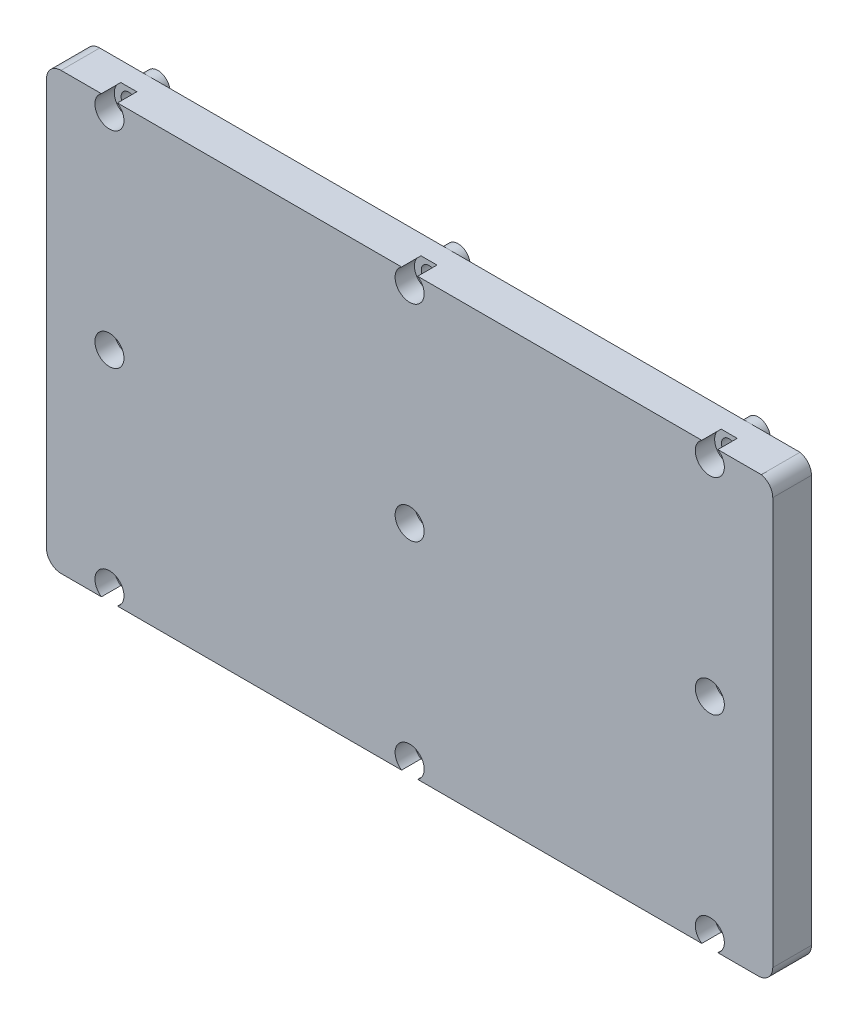
from build123d import *

# Parameters (mm, degrees)
BOSS_EXTRU_1_DEPTH           = 8
ESQUISSE14_R                 = 1.6
ENL_V_MAT_EXTRU_2_DEPTH      = 1
ENL_V_MAT_EXTRU_2_DEPTH_BACK = 9
ESQUISSE15_R                 = 3
ENL_V_MAT_EXTRU_3_DEPTH      = 4
ESQUISSE16_R                 = 2.5
BOSS_EXTRU_3_DEPTH           = 2
ESQUISSE17_R                 = 1.6
ENL_V_MAT_EXTRU_4_DEPTH      = 11


with BuildPart() as part:
    # Esquisse1 → Boss.-Extru.1 (new body)
    with BuildSketch(Plane.XY):
        with BuildLine():
            Line((2.96841177, 10.030192742), (146.96841177, 10.030192742))
            ThreePointArc((146.96841177, 10.030192742), (149.089732114, 10.908872398), (149.96841177, 13.030192742))
            Line((149.96841177, 13.030192742), (149.96841177, 97.09690847))
            ThreePointArc((149.96841177, 97.09690847), (149.301594422, 98.982712998), (147.597572626, 100.030192742))
            Line((147.597572626, 100.030192742), (2.96841177, 100.030192742))
            ThreePointArc((2.96841177, 100.030192742), (0.847091427, 99.151513085), (-0.03158823, 97.030192742))
            Line((-0.03158823, 97.030192742), (-0.03158823, 13.030192742))
            ThreePointArc((-0.03158823, 13.030192742), (0.847091427, 10.908872398), (2.96841177, 10.030192742))
        make_face()
    extrude(amount=BOSS_EXTRU_1_DEPTH)

    # Esquisse14 → Enlèv. mat.-Extru.2 (cut, two sides)
    with BuildSketch(Plane.XY.offset(8)) as enl_v_mat_extru_2_sk:
        with Locations((12.96841177, 97.530192742)):
            Circle(ESQUISSE14_R)
        with Locations((74.96841177, 97.530192742)):
            Circle(ESQUISSE14_R)
        with Locations((136.96841177, 97.530192742)):
            Circle(ESQUISSE14_R)
        with Locations((136.96841177, 55.030192742)):
            Circle(ESQUISSE14_R)
        with Locations((74.96841177, 55.030192742)):
            Circle(ESQUISSE14_R)
        with Locations((12.96841177, 55.030192742)):
            Circle(ESQUISSE14_R)
        with Locations((12.96841177, 12.530192742)):
            Circle(ESQUISSE14_R)
        with Locations((74.96841177, 12.530192742)):
            Circle(ESQUISSE14_R)
        with Locations((136.96841177, 12.530192742)):
            Circle(ESQUISSE14_R)
    extrude(amount=ENL_V_MAT_EXTRU_2_DEPTH, mode=Mode.SUBTRACT)
    extrude(enl_v_mat_extru_2_sk.sketch, amount=-ENL_V_MAT_EXTRU_2_DEPTH_BACK, mode=Mode.SUBTRACT)

    # Esquisse15 → Enlèv. mat.-Extru.3 (cut)
    with BuildSketch(Plane.XY.offset(8)):
        with Locations((12.96841177, 97.530192742)):
            Circle(ESQUISSE15_R)
        with Locations((12.96841177, 12.530192742)):
            Circle(ESQUISSE15_R)
        with Locations((74.96841177, 12.530192742)):
            Circle(ESQUISSE15_R)
        with Locations((136.96841177, 12.530192742)):
            Circle(ESQUISSE15_R)
        with Locations((136.96841177, 55.030192742)):
            Circle(ESQUISSE15_R)
        with Locations((74.96841177, 55.030192742)):
            Circle(ESQUISSE15_R)
        with Locations((12.96841177, 55.030192742)):
            Circle(ESQUISSE15_R)
        with Locations((74.96841177, 97.530192742)):
            Circle(ESQUISSE15_R)
        with Locations((136.96841177, 97.530192742)):
            Circle(ESQUISSE15_R)
    extrude(amount=-ENL_V_MAT_EXTRU_3_DEPTH, mode=Mode.SUBTRACT)

    # Esquisse16 → Boss.-Extru.3 (add)
    with BuildSketch(Plane(origin=(0, 0, 0), x_dir=(-1, 0, 0), z_dir=(0, 0, -1))):
        with Locations((-136.96841177, 97.530192742)):
            Circle(ESQUISSE16_R)
        with Locations((-74.96841177, 97.530192742)):
            Circle(ESQUISSE16_R)
        with Locations((-12.96841177, 97.530192742)):
            Circle(ESQUISSE16_R)
        with Locations((-12.96841177, 55.030192742)):
            Circle(ESQUISSE16_R)
        with Locations((-74.96841177, 55.030192742)):
            Circle(ESQUISSE16_R)
        with Locations((-136.96841177, 55.030192742)):
            Circle(ESQUISSE16_R)
        with Locations((-136.96841177, 12.530192742)):
            Circle(ESQUISSE16_R)
        with Locations((-74.96841177, 12.530192742)):
            Circle(ESQUISSE16_R)
        with Locations((-12.96841177, 12.530192742)):
            Circle(ESQUISSE16_R)
    extrude(amount=BOSS_EXTRU_3_DEPTH)

    # Esquisse17 → Enlèv. mat.-Extru.4 (cut, through all)
    with BuildSketch(Plane(origin=(0, 0, -2), x_dir=(-1, 0, 0), z_dir=(0, 0, -1))):
        with Locations((-136.96841177, 97.530192742)):
            Circle(ESQUISSE17_R)
        with Locations((-136.96841177, 55.030192742)):
            Circle(ESQUISSE17_R)
        with Locations((-136.96841177, 12.530192742)):
            Circle(ESQUISSE17_R)
        with Locations((-74.96841177, 12.530192742)):
            Circle(ESQUISSE17_R)
        with Locations((-74.96841177, 55.030192742)):
            Circle(ESQUISSE17_R)
        with Locations((-74.96841177, 97.530192742)):
            Circle(ESQUISSE17_R)
        with Locations((-12.96841177, 97.530192742)):
            Circle(ESQUISSE17_R)
        with Locations((-12.96841177, 55.030192742)):
            Circle(ESQUISSE17_R)
        with Locations((-12.96841177, 12.530192742)):
            Circle(ESQUISSE17_R)
    extrude(amount=-ENL_V_MAT_EXTRU_4_DEPTH, mode=Mode.SUBTRACT)


solid = part.part
